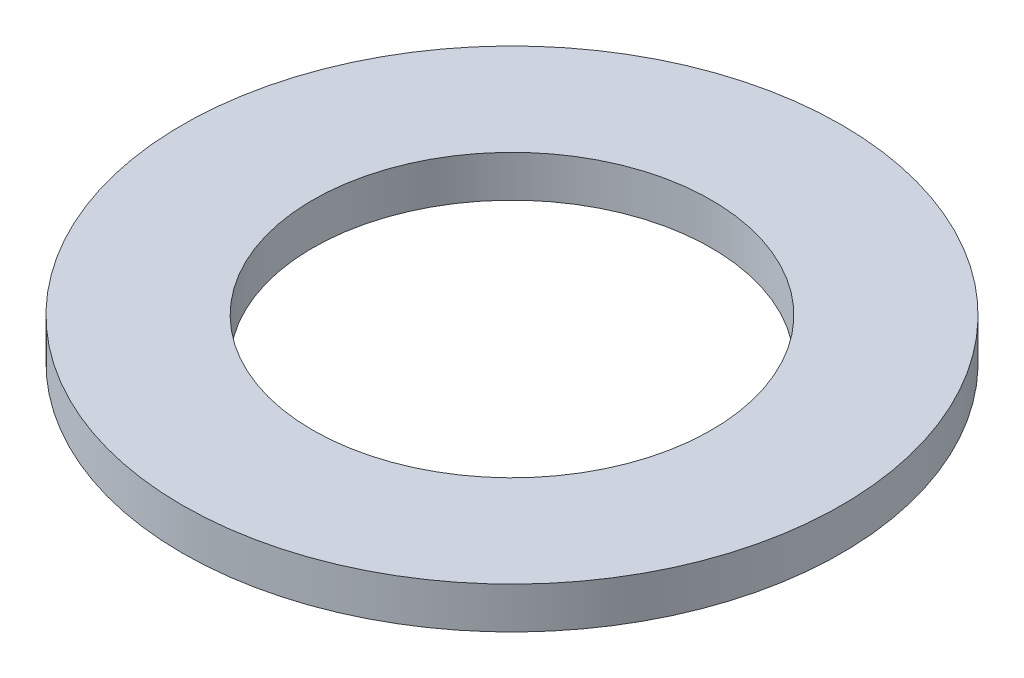
from build123d import *

# Parameters (mm, degrees)
SKETCH1_R           = 15.748
BOSS_EXTRUDE1_DEPTH = 1.9812
SKETCH2_R           = 9.525
CUT_EXTRUDE1_DEPTH  = 4.5212


with BuildPart() as part:
    # Sketch1 → Boss-Extrude1 (new body)
    with BuildSketch(Plane(origin=(0, 0, 0), x_dir=(1, 0, 0), z_dir=(0, 1, 0))):
        Circle(SKETCH1_R)
    extrude(amount=BOSS_EXTRUDE1_DEPTH)

    # Sketch2 → Cut-Extrude1 (cut)
    with BuildSketch(Plane(origin=(0, 1.9812, 0), x_dir=(1, 0, 0), z_dir=(0, 1, 0))):
        Circle(SKETCH2_R)
    extrude(amount=-CUT_EXTRUDE1_DEPTH, mode=Mode.SUBTRACT)


solid = part.part
